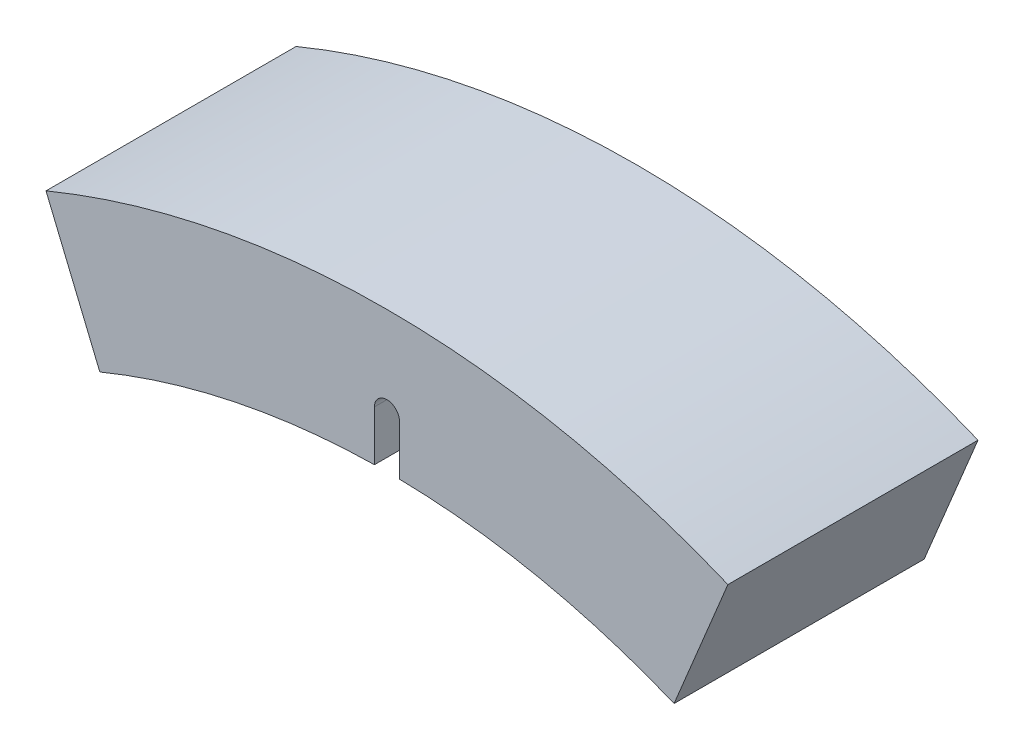
from build123d import *

# Parameters (mm, degrees)
BOSS_EXTRUDE3_DEPTH      = 20
BOSS_EXTRUDE3_DEPTH_BACK = 20
BOSS_EXTRUDE5_DEPTH      = 10
BOSS_EXTRUDE5_DEPTH_BACK = 10
SKETCH2_8_R              = 1.25


with BuildPart() as part:
    # Sketch2 → Boss-Extrude3 (new, two sides: drawn at the far end of the back side and taken through both)
    with BuildSketch(Plane.XY.offset(11).offset(-BOSS_EXTRUDE3_DEPTH_BACK)):
        with BuildLine():
            ThreePointArc((2, 119.983332176), (24.390845035, 117.495049591), (45.922011884, 110.865543901))
            Line((45.922011884, 110.865543901), (54.532389112, 131.652833383))
            ThreePointArc((54.532389112, 131.652833383), (0, 142.5), (-54.532389112, 131.652833383))
            Line((-54.532389112, 131.652833383), (-45.922011884, 110.865543901))
            ThreePointArc((-45.922011884, 110.865543901), (-24.390845035, 117.495049591), (-2, 119.983332176))
            Line((-2, 119.983332176), (-2, 128))
            ThreePointArc((-2, 128), (0, 130), (2, 128))
            Line((2, 128), (2, 119.983332176))
        make_face()
    extrude(amount=BOSS_EXTRUDE3_DEPTH + BOSS_EXTRUDE3_DEPTH_BACK)

    # Sketch2_8 → Boss-Extrude5 (add, two sides: drawn at the far end of the back side and taken through both)
    with BuildSketch(Plane.XY.offset(11).offset(-BOSS_EXTRUDE5_DEPTH_BACK)):
        with BuildLine():
            ThreePointArc((-2, 119.983332176), (0, 120), (2, 119.983332176))
            Line((2, 119.983332176), (2, 128))
            ThreePointArc((2, 128), (0, 130), (-2, 128))
            Line((-2, 128), (-2, 119.983332176))
        make_face()
        with Locations((0, 128)):
            Circle(SKETCH2_8_R, mode=Mode.SUBTRACT)
    extrude(amount=BOSS_EXTRUDE5_DEPTH + BOSS_EXTRUDE5_DEPTH_BACK)


solid = part.part
